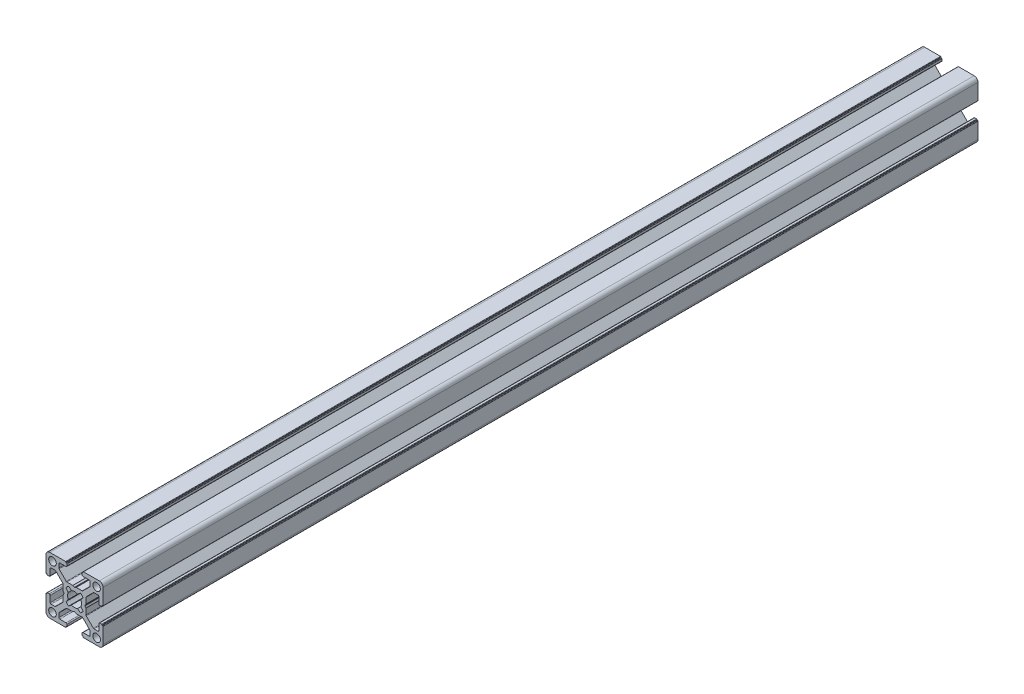
from build123d import *

# Parameters (mm, degrees)
CROQUIS1_R              = 2
SALIENTE_EXTRUIR1_DEPTH = 460


with BuildPart() as part:
    # Croquis1 → Saliente-Extruir1 (new body)
    with BuildSketch(Plane.XY.offset(1000)):
        with BuildLine():
            Line((9.800000436, -10.500000436), (10.100000436, -10.500000436))
            ThreePointArc((10.100000436, -10.500000436), (10.241421792, -10.441421792), (10.300000436, -10.300000436))
            Line((10.300000436, -10.300000436), (10.300000436, -2))
            ThreePointArc((10.300000436, -2), (9.714213998, -0.585786438), (8.300000436, 0))
            Line((8.300000436, 0), (0, 0))
            ThreePointArc((0, 0), (-0.141421356, -0.058578644), (-0.2, -0.2))
            Line((-0.2, -0.2), (-0.2, -0.5))
            Line((-0.2, -0.5), (-0.49999919, -0.5))
            ThreePointArc((-0.49999919, -0.5), (-0.641420811, -0.558578753), (-0.699999564, -0.700000374))
            Line((-0.699999564, -0.700000374), (-0.699999564, -1.700000763))
            ThreePointArc((-0.699999564, -1.700000763), (-0.553552955, -2.053554154), (-0.199999564, -2.200000763))
            Line((-0.199999564, -2.200000763), (3.050000763, -2.200000763))
            ThreePointArc((3.050000763, -2.200000763), (3.403554154, -2.346447372), (3.550000763, -2.700000763))
            Line((3.550000763, -2.700000763), (3.550000763, -4.743055509))
            ThreePointArc((3.550000763, -4.743055509), (3.511993279, -4.934269826), (3.403749103, -5.096413843))
            Line((3.403749103, -5.096413843), (-0.349053376, -8.853358334))
            ThreePointArc((-0.349053376, -8.853358334), (-0.511332616, -8.961886981), (-0.702801716, -9))
            Line((-0.702801716, -9), (-3.746809419, -9))
            ThreePointArc((-3.746809419, -9), (-3.798212795, -9.006718618), (-3.846162576, -9.026423071))
            Line((-3.846162576, -9.026423071), (-4.600646407, -9.458279719))
            ThreePointArc((-4.600646407, -9.458279719), (-4.699999564, -9.48470279), (-4.799352721, -9.458279719))
            Line((-4.799352721, -9.458279719), (-5.553836552, -9.026423071))
            ThreePointArc((-5.553836552, -9.026423071), (-5.601786333, -9.006718618), (-5.653189709, -9))
            Line((-5.653189709, -9), (-8.697197412, -9))
            ThreePointArc((-8.697197412, -9), (-8.888666513, -8.961886981), (-9.050945752, -8.853358334))
            Line((-9.050945752, -8.853358334), (-12.803748231, -5.096413843))
            ThreePointArc((-12.803748231, -5.096413843), (-12.911992407, -4.934269826), (-12.949999891, -4.743055509))
            Line((-12.949999891, -4.743055509), (-12.949999891, -2.700000763))
            ThreePointArc((-12.949999891, -2.700000763), (-12.803553282, -2.346447372), (-12.449999891, -2.200000763))
            Line((-12.449999891, -2.200000763), (-9.199999564, -2.200000763))
            ThreePointArc((-9.199999564, -2.200000763), (-8.846446173, -2.053554154), (-8.699999564, -1.700000763))
            Line((-8.699999564, -1.700000763), (-8.699999564, -0.700000374))
            ThreePointArc((-8.699999564, -0.700000374), (-8.758578317, -0.558578753), (-8.899999938, -0.5))
            Line((-8.899999938, -0.5), (-9.199999128, -0.5))
            Line((-9.199999128, -0.5), (-9.199999128, -0.2))
            ThreePointArc((-9.199999128, -0.2), (-9.258577772, -0.058578644), (-9.399999128, 0))
            Line((-9.399999128, 0), (-17.699999564, 0))
            ThreePointArc((-17.699999564, 0), (-19.114213126, -0.585786438), (-19.699999564, -2))
            Line((-19.699999564, -2), (-19.699999564, -10.300000436))
            ThreePointArc((-19.699999564, -10.300000436), (-19.64142092, -10.441421792), (-19.499999564, -10.500000436))
            Line((-19.499999564, -10.500000436), (-19.199999564, -10.500000436))
            Line((-19.199999564, -10.500000436), (-19.199999564, -10.799999627))
            ThreePointArc((-19.199999564, -10.799999627), (-19.141420811, -10.941421247), (-18.99999919, -11))
            Line((-18.99999919, -11), (-17.999998801, -11))
            ThreePointArc((-17.999998801, -11), (-17.64644541, -10.853553391), (-17.499998801, -10.5))
            Line((-17.499998801, -10.5), (-17.499998801, -7.249999673))
            ThreePointArc((-17.499998801, -7.249999673), (-17.353552192, -6.896446283), (-16.999998801, -6.749999673))
            Line((-16.999998801, -6.749999673), (-14.956944055, -6.749999673))
            ThreePointArc((-14.956944055, -6.749999673), (-14.765729738, -6.788007157), (-14.603585721, -6.896251334))
            Line((-14.603585721, -6.896251334), (-10.84664123, -10.649053813))
            ThreePointArc((-10.84664123, -10.649053813), (-10.738112583, -10.811333052), (-10.699999564, -11.002802152))
            Line((-10.699999564, -11.002802152), (-10.699999564, -14.046809855))
            ThreePointArc((-10.699999564, -14.046809855), (-10.693280947, -14.098213232), (-10.673576493, -14.146163012))
            Line((-10.673576493, -14.146163012), (-10.241719845, -14.900646843))
            ThreePointArc((-10.241719845, -14.900646843), (-10.215296774, -15), (-10.241719845, -15.099353157))
            Line((-10.241719845, -15.099353157), (-10.673576493, -15.853836988))
            ThreePointArc((-10.673576493, -15.853836988), (-10.693280947, -15.901786769), (-10.699999564, -15.953190146))
            Line((-10.699999564, -15.953190146), (-10.699999564, -18.997197848))
            ThreePointArc((-10.699999564, -18.997197848), (-10.738112583, -19.188666949), (-10.84664123, -19.350946188))
            Line((-10.84664123, -19.350946188), (-14.603585721, -23.103748667))
            ThreePointArc((-14.603585721, -23.103748667), (-14.765729738, -23.211992843), (-14.956944055, -23.250000327))
            Line((-14.956944055, -23.250000327), (-16.999998801, -23.250000327))
            ThreePointArc((-16.999998801, -23.250000327), (-17.353552192, -23.103553718), (-17.499998801, -22.750000327))
            Line((-17.499998801, -22.750000327), (-17.499998801, -19.5))
            ThreePointArc((-17.499998801, -19.5), (-17.64644541, -19.14644661), (-17.999998801, -19))
            Line((-17.999998801, -19), (-18.99999919, -19))
            ThreePointArc((-18.99999919, -19), (-19.141420811, -19.058578753), (-19.199999564, -19.200000374))
            Line((-19.199999564, -19.200000374), (-19.199999564, -19.499999564))
            Line((-19.199999564, -19.499999564), (-19.499999564, -19.499999564))
            ThreePointArc((-19.499999564, -19.499999564), (-19.64142092, -19.558578208), (-19.699999564, -19.699999564))
            Line((-19.699999564, -19.699999564), (-19.699999564, -28))
            ThreePointArc((-19.699999564, -28), (-19.114213126, -29.414213563), (-17.699999564, -30))
            Line((-17.699999564, -30), (-9.399999128, -30))
            ThreePointArc((-9.399999128, -30), (-9.258577772, -29.941421356), (-9.199999128, -29.8))
            Line((-9.199999128, -29.8), (-9.199999128, -29.5))
            Line((-9.199999128, -29.5), (-8.899999938, -29.5))
            ThreePointArc((-8.899999938, -29.5), (-8.758578317, -29.441421247), (-8.699999564, -29.299999627))
            Line((-8.699999564, -29.299999627), (-8.699999564, -28.299999237))
            ThreePointArc((-8.699999564, -28.299999237), (-8.846446173, -27.946445847), (-9.199999564, -27.799999237))
            Line((-9.199999564, -27.799999237), (-12.449999891, -27.799999237))
            ThreePointArc((-12.449999891, -27.799999237), (-12.803553282, -27.653552628), (-12.949999891, -27.299999237))
            Line((-12.949999891, -27.299999237), (-12.949999891, -25.256944491))
            ThreePointArc((-12.949999891, -25.256944491), (-12.911992407, -25.065730174), (-12.803748231, -24.903586157))
            Line((-12.803748231, -24.903586157), (-9.050945752, -21.146641666))
            ThreePointArc((-9.050945752, -21.146641666), (-8.888666513, -21.038113019), (-8.697197412, -21))
            Line((-8.697197412, -21), (-5.653189709, -21))
            ThreePointArc((-5.653189709, -21), (-5.601786333, -20.993281383), (-5.553836552, -20.973576929))
            Line((-5.553836552, -20.973576929), (-4.799352721, -20.541720281))
            ThreePointArc((-4.799352721, -20.541720281), (-4.699999564, -20.51529721), (-4.600646407, -20.541720281))
            Line((-4.600646407, -20.541720281), (-3.846162576, -20.973576929))
            ThreePointArc((-3.846162576, -20.973576929), (-3.798212795, -20.993281383), (-3.746809419, -21))
            Line((-3.746809419, -21), (-0.702801716, -21))
            ThreePointArc((-0.702801716, -21), (-0.511332616, -21.038113019), (-0.349053377, -21.146641666))
            Line((-0.349053377, -21.146641666), (3.403749103, -24.903586157))
            ThreePointArc((3.403749103, -24.903586157), (3.511993279, -25.065730174), (3.550000763, -25.256944491))
            Line((3.550000763, -25.256944491), (3.550000763, -27.299999237))
            ThreePointArc((3.550000763, -27.299999237), (3.403554154, -27.653552628), (3.050000763, -27.799999237))
            Line((3.050000763, -27.799999237), (-0.199999564, -27.799999237))
            ThreePointArc((-0.199999564, -27.799999237), (-0.553552955, -27.946445847), (-0.699999564, -28.299999237))
            Line((-0.699999564, -28.299999237), (-0.699999564, -29.299999627))
            ThreePointArc((-0.699999564, -29.299999627), (-0.641420811, -29.441421247), (-0.49999919, -29.5))
            Line((-0.49999919, -29.5), (-0.2, -29.5))
            Line((-0.2, -29.5), (-0.2, -29.8))
            ThreePointArc((-0.2, -29.8), (-0.141421356, -29.941421356), (0, -30))
            Line((0, -30), (8.300000436, -30))
            ThreePointArc((8.300000436, -30), (9.714213998, -29.414213563), (10.300000436, -28))
            Line((10.300000436, -28), (10.300000436, -19.699999564))
            ThreePointArc((10.300000436, -19.699999564), (10.241421792, -19.558578208), (10.100000436, -19.499999564))
            Line((10.100000436, -19.499999564), (9.800000436, -19.499999564))
            Line((9.800000436, -19.499999564), (9.800000436, -19.200000374))
            ThreePointArc((9.800000436, -19.200000374), (9.741421683, -19.058578753), (9.600000062, -19))
            Line((9.600000062, -19), (8.599999673, -19))
            ThreePointArc((8.599999673, -19), (8.246446283, -19.14644661), (8.099999673, -19.5))
            Line((8.099999673, -19.5), (8.099999673, -22.750000327))
            ThreePointArc((8.099999673, -22.750000327), (7.953553064, -23.103553718), (7.599999673, -23.250000327))
            Line((7.599999673, -23.250000327), (5.556944927, -23.250000327))
            ThreePointArc((5.556944927, -23.250000327), (5.36573061, -23.211992843), (5.203586593, -23.103748667))
            Line((5.203586593, -23.103748667), (1.446642102, -19.350946188))
            ThreePointArc((1.446642102, -19.350946188), (1.338113455, -19.188666949), (1.300000436, -18.997197848))
            Line((1.300000436, -18.997197848), (1.300000436, -15.953190145))
            ThreePointArc((1.300000436, -15.953190145), (1.293281819, -15.901786769), (1.273577365, -15.853836988))
            Line((1.273577365, -15.853836988), (0.841720717, -15.099353157))
            ThreePointArc((0.841720717, -15.099353157), (0.815297646, -15), (0.841720717, -14.900646843))
            Line((0.841720717, -14.900646843), (1.273577365, -14.146163012))
            ThreePointArc((1.273577365, -14.146163012), (1.293281819, -14.098213231), (1.300000436, -14.046809855))
            Line((1.300000436, -14.046809855), (1.300000436, -11.002802152))
            ThreePointArc((1.300000436, -11.002802152), (1.338113455, -10.811333052), (1.446642102, -10.649053813))
            Line((1.446642102, -10.649053813), (5.203586593, -6.896251334))
            ThreePointArc((5.203586593, -6.896251334), (5.36573061, -6.788007157), (5.556944927, -6.749999673))
            Line((5.556944927, -6.749999673), (7.599999673, -6.749999673))
            ThreePointArc((7.599999673, -6.749999673), (7.953553064, -6.896446283), (8.099999673, -7.249999673))
            Line((8.099999673, -7.249999673), (8.099999673, -10.5))
            ThreePointArc((8.099999673, -10.5), (8.246446283, -10.853553391), (8.599999673, -11))
            Line((8.599999673, -11), (9.600000062, -11))
            ThreePointArc((9.600000062, -11), (9.741421683, -10.941421247), (9.800000436, -10.799999627))
            Line((9.800000436, -10.799999627), (9.800000436, -10.500000436))
        make_face()
        with Locations((-16.300000272, -3.399999983)):
            Circle(CROQUIS1_R, mode=Mode.SUBTRACT)
        with Locations((6.900001145, -3.399999983)):
            Circle(CROQUIS1_R, mode=Mode.SUBTRACT)
        with Locations((-16.300000272, -26.600000017)):
            Circle(CROQUIS1_R, mode=Mode.SUBTRACT)
        with Locations((6.900001145, -26.600000017)):
            Circle(CROQUIS1_R, mode=Mode.SUBTRACT)
        with BuildLine():
            Line((-7.835928976, -10.481599097), (-6.300129088, -11.719438233))
            ThreePointArc((-6.300129088, -11.719438233), (-4.699999564, -11.35), (-3.09987004, -11.719438233))
            Line((-3.09987004, -11.719438233), (-1.564070152, -10.481599097))
            ThreePointArc((-1.564070152, -10.481599097), (-0.818997305, -11.10284444), (-0.194662672, -11.845330527))
            Line((-0.194662672, -11.845330527), (-1.419437832, -13.399870404))
            ThreePointArc((-1.419437832, -13.399870404), (-1.049999564, -15), (-1.419437832, -16.600129597))
            Line((-1.419437832, -16.600129597), (-0.194662672, -18.154669473))
            ThreePointArc((-0.194662672, -18.154669473), (-0.818997305, -18.897155561), (-1.564070152, -19.518400903))
            Line((-1.564070152, -19.518400903), (-3.09987004, -18.280561767))
            ThreePointArc((-3.09987004, -18.280561767), (-4.699999564, -18.65), (-6.300129088, -18.280561767))
            Line((-6.300129088, -18.280561767), (-7.835928976, -19.518400903))
            ThreePointArc((-7.835928976, -19.518400903), (-8.581001823, -18.897155561), (-9.205336456, -18.154669473))
            Line((-9.205336456, -18.154669473), (-7.980561295, -16.600129597))
            ThreePointArc((-7.980561295, -16.600129597), (-8.349999564, -15), (-7.980561296, -13.399870404))
            Line((-7.980561296, -13.399870404), (-9.205336456, -11.845330527))
            ThreePointArc((-9.205336456, -11.845330527), (-8.581001823, -11.10284444), (-7.835928976, -10.481599097))
        make_face(mode=Mode.SUBTRACT)
    extrude(amount=-SALIENTE_EXTRUIR1_DEPTH)


solid = part.part
